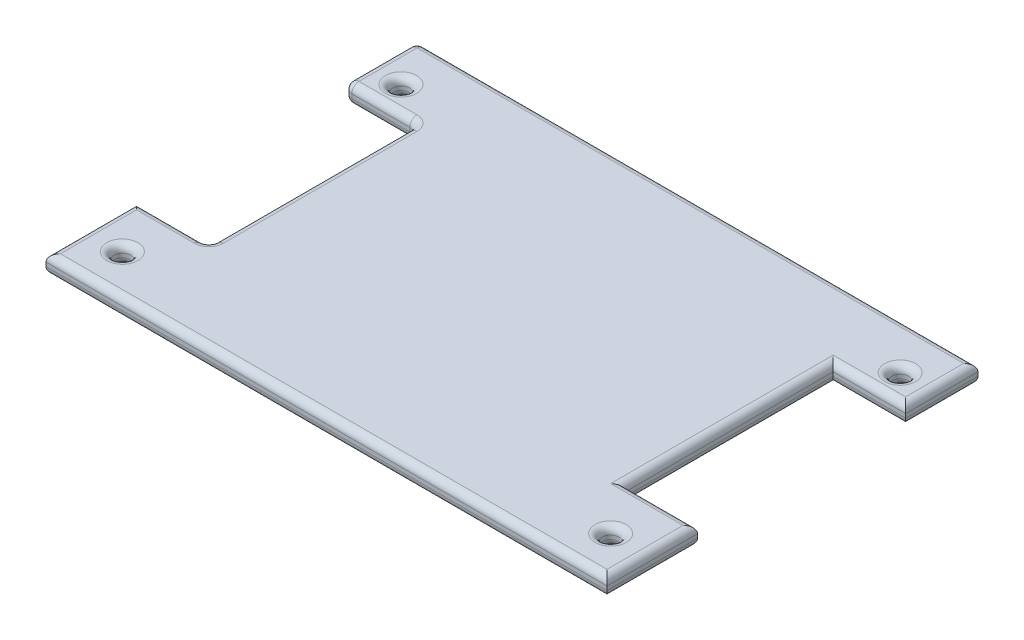
from build123d import *

# Parameters (mm, degrees)
BOSS_EXTRUDE1_DEPTH = 5.08
SKETCH2_R           = 2.3
CUT_EXTRUDE1_DEPTH  = 5.08
FILLET1_R           = 2


with BuildPart() as part:
    # Sketch1 → Boss-Extrude1 (new body)
    with BuildSketch(Plane(origin=(0, 0, 0), x_dir=(1, 0, 0), z_dir=(0, 1, 0))):
        Polygon((-77.5, 0), (0, 0), (0, 102.5), (-77.5, 102.5), (-77.5, 82.5), (-57.5, 82.5), (-57.5, 25), (-77.5, 25), align=None)
        Polygon((0, 0), (77.5, 0), (77.5, 25), (57.5, 25), (57.5, 82.5), (77.5, 82.5), (77.5, 102.5), (0, 102.5), align=None)
    extrude(amount=BOSS_EXTRUDE1_DEPTH)

    # Sketch2 → Cut-Extrude1 (cut)
    with BuildSketch(Plane(origin=(0, 5.08, 0), x_dir=(1, 0, 0), z_dir=(0, 1, 0))):
        with Locations((-68.95, 89.55)):
            Circle(SKETCH2_R)
        with Locations((68.95, 89.55)):
            Circle(SKETCH2_R)
        with Locations((-67.45, 11.05)):
            Circle(SKETCH2_R)
        with Locations((67.45, 11.05)):
            Circle(SKETCH2_R)
    extrude(amount=-CUT_EXTRUDE1_DEPTH, mode=Mode.SUBTRACT)

    # Fillet1
    fillet1_edges = [part.edges().sort_by_distance(p)[0] for p in [
        (-77.5, 5.08, -12.5),
        (-57.5, 0, -53.75),
        (-67.5, 0, -82.5),
        (-77.5, 0, -92.5),
        (0, 5.08, 0),
        (0, 0, -102.5),
        (77.5, 0, -92.5),
        (67.5, 0, -82.5),
        (57.5, 0, -53.75),
        (67.5, 0, -25),
        (77.5, 0, -12.5),
        (0, 0, 0),
        (-77.5, 0, -12.5),
        (-67.5, 0, -25),
        (77.5, 5.08, -12.5),
        (-57.5, 2.54, -25),
        (-57.5, 2.54, -82.5),
        (-77.5, 2.54, -82.5),
        (-77.5, 2.54, -102.5),
        (67.5, 5.08, -25),
        (57.5, 5.08, -53.75),
        (67.5, 5.08, -82.5),
        (77.5, 5.08, -92.5),
        (0, 5.08, -102.5),
        (66.65, 5.08, -89.55),
        (-67.5, 5.08, -25),
        (66.65, 0, -89.55),
        (-69.75, 5.08, -11.05),
        (-77.5, 5.08, -92.5),
        (-69.75, 0, -11.05),
        (65.15, 5.08, -11.05),
        (65.15, 0, -11.05),
        (-71.25, 5.08, -89.55),
        (-71.25, 0, -89.55),
        (-67.5, 5.08, -82.5),
        (-57.5, 5.08, -53.75),
    ]]
    fillet(fillet1_edges, radius=FILLET1_R)


solid = part.part
